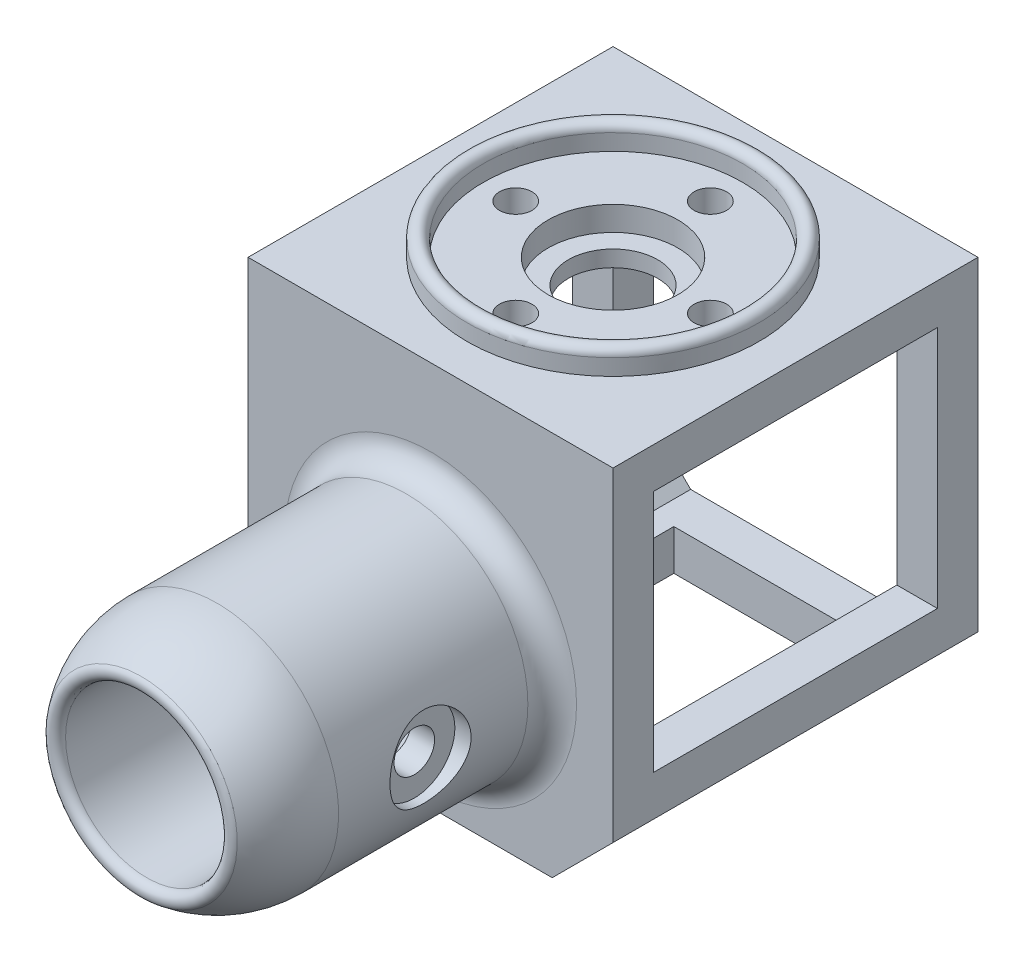
from build123d import *

# Parameters (mm, degrees)
BOSS_EXTRUDE2_DEPTH                      = 45
SHELL1_T                                 = 5
CUT_EXTRUDE1_REACH                       = 47
SKETCH7_W                                = 35
SKETCH7_H                                = 30
CUT_EXTRUDE2_DEPTH                       = 46
CUT_EXTRUDE5_REACH                       = 49.5
SKETCH9_W                                = 20
SKETCH9_H                                = 35
CBORE_FOR_M16_HEX_HEAD_BOLT1_D           = 11
CBORE_FOR_M16_HEX_HEAD_BOLT1_DEPTH       = 5
CBORE_FOR_M16_HEX_HEAD_BOLT1_CBORE_D     = 16
CBORE_FOR_M16_HEX_HEAD_BOLT1_CBORE_DEPTH = 3
CBORE_FOR_M16_HEX_HEAD_BOLT1_TIP         = 3.304733405
CUT_EXTRUDE6_REACH                       = 49.5
SKETCH11_R                               = 2
FILLET1_R                                = 3
CUT_EXTRUDE10_REACH                      = 47
SKETCH15_R                               = 10
CBORE_FOR_M5_HEX_HEAD_BOLT1_D            = 5
CBORE_FOR_M5_HEX_HEAD_BOLT1_CBORE_D      = 10
CBORE_FOR_M5_HEX_HEAD_BOLT1_CBORE_DEPTH  = 2


with BuildPart() as part:
    # Sketch5 → Boss-Extrude2 (new body)
    with BuildSketch(Plane.XY):
        Polygon((-15, -20), (15, -20), (22.5, -12.5), (22.5, 27.5), (-22.5, 27.5), (-22.5, -12.5), align=None)
    extrude(amount=-BOSS_EXTRUDE2_DEPTH)

    # Shell1 (no face opened: a closed hollow body)
    add(offset(amount=-SHELL1_T, mode=Mode.PRIVATE), mode=Mode.SUBTRACT)

    # Sketch6 → Cut-Extrude1 (cut, up to next)
    with BuildSketch(Plane(origin=(0, 0, -45), x_dir=(-1, 0, 0), z_dir=(0, 0, -1)), mode=Mode.PRIVATE) as cut_extrude1_sk1:
        Polygon((12.928932188, -15), (17.5, -10.428932188), (17.5, 22.5), (-17.5, 22.5), (-17.5, -10.428932188), (-12.928932188, -15), align=None)
    cut_extrude1_tool1 = extrude(cut_extrude1_sk1.sketch, amount=-CUT_EXTRUDE1_REACH, mode=Mode.PRIVATE) & part.part
    add(cut_extrude1_tool1.solids().sort_by_distance((0, 4.028675, -45))[0], mode=Mode.SUBTRACT)

    # Sketch7 → Cut-Extrude2 (cut, through all)
    with BuildSketch(Plane(origin=(22.5, 0, 0), x_dir=(0, 0, -1), z_dir=(1, 0, 0))):
        with Locations((22.5, 7.5)):
            Rectangle(SKETCH7_W, SKETCH7_H)
    extrude(amount=-CUT_EXTRUDE2_DEPTH, mode=Mode.SUBTRACT)

    # Sketch9 → Cut-Extrude5 (cut, up to next)
    with BuildSketch(Plane.XZ.offset(20), mode=Mode.PRIVATE) as cut_extrude5_sk1:
        with Locations((0, -22.5)):
            Rectangle(SKETCH9_W, SKETCH9_H)
    cut_extrude5_tool1 = extrude(cut_extrude5_sk1.sketch, amount=-CUT_EXTRUDE5_REACH, mode=Mode.PRIVATE) & part.part
    add(cut_extrude5_tool1.solids().sort_by_distance((0, -20, -22.5))[0], mode=Mode.SUBTRACT)

    # Sketch1 → Revolve1 (revolve)
    with BuildSketch(Plane(origin=(0, 0, 0), x_dir=(0, 0, -1), z_dir=(1, 0, 0)), mode=Mode.PRIVATE) as revolve1_sk:
        with BuildLine():
            Line((0, 10), (-35, 10))
            ThreePointArc((-35, 10), (-35.944911183, 10.672673165), (-35.618589574, 11.785714286))
            ThreePointArc((-35.618589574, 11.785714286), (-31.249648492, 14.173667738), (-26.339745962, 15))
            Line((-26.339745962, 15), (0, 15))
            Line((0, 15), (0, 10))
        make_face()
    revolve(revolve1_sk.sketch.rotate(Axis((0, 0, 0), (0, 0, 1)), 90), axis=Axis((0, 0, 0), (0, 0, 1)))  # turned: the seam where the file's is

    # Sketch10 → Revolve2 (revolve)
    with BuildSketch(Plane(origin=(0, 0, 0), x_dir=(0, 0, -1), z_dir=(1, 0, 0))):
        with BuildLine():
            Line((38.5, 27.5), (38.5, 29.5))
            ThreePointArc((38.5, 29.5), (39.5, 30.5), (40.5, 29.5))
            Line((40.5, 29.5), (40.5, 27.5))
            Line((40.5, 27.5), (38.5, 27.5))
        make_face()
    revolve(axis=Axis((0, 27.5, -22.5), (0, 1, 0)))

    # CBORE for M16 Hex Head Bolt1
    with Locations(Plane(origin=(0, 27.5, 0), x_dir=(1, 0, 0), z_dir=(0, 1, 0))):
        with Locations((0, 22.5)):
            CounterBoreHole(CBORE_FOR_M16_HEX_HEAD_BOLT1_D / 2, CBORE_FOR_M16_HEX_HEAD_BOLT1_CBORE_D / 2, CBORE_FOR_M16_HEX_HEAD_BOLT1_CBORE_DEPTH, depth=CBORE_FOR_M16_HEX_HEAD_BOLT1_DEPTH)
            with Locations((0, 0, -(CBORE_FOR_M16_HEX_HEAD_BOLT1_DEPTH + CBORE_FOR_M16_HEX_HEAD_BOLT1_TIP / 2))):  # 118° drill point
                Cone(0, CBORE_FOR_M16_HEX_HEAD_BOLT1_D / 2, CBORE_FOR_M16_HEX_HEAD_BOLT1_TIP, mode=Mode.SUBTRACT)

    # Sketch11 → Cut-Extrude6 (cut, up to next)
    with BuildSketch(Plane(origin=(0, 27.5, 0), x_dir=(1, 0, 0), z_dir=(0, 1, 0)), mode=Mode.PRIVATE) as cut_extrude6_sk1:
        with Locations(Location((12, 22.5, 0), (0, 0, 270))):  # turned: the seam where the file's is
            Circle(SKETCH11_R)
    cut_extrude6_tool1 = extrude(cut_extrude6_sk1.sketch, amount=-CUT_EXTRUDE6_REACH, mode=Mode.PRIVATE) & part.part
    add(cut_extrude6_tool1.solids().sort_by_distance((12, 27.5, -22.5))[0], mode=Mode.SUBTRACT)
    # Sketch11 → Cut-Extrude6 (cut, up to next)
    with BuildSketch(Plane(origin=(0, 27.5, 0), x_dir=(1, 0, 0), z_dir=(0, 1, 0)), mode=Mode.PRIVATE) as cut_extrude6_sk2:
        with Locations(Location((0, 10.5, 0), (0, 0, 270))):  # turned: the seam where the file's is
            Circle(SKETCH11_R)
    cut_extrude6_tool2 = extrude(cut_extrude6_sk2.sketch, amount=-CUT_EXTRUDE6_REACH, mode=Mode.PRIVATE) & part.part
    add(cut_extrude6_tool2.solids().sort_by_distance((0, 27.5, -10.5))[0], mode=Mode.SUBTRACT)
    # Sketch11 → Cut-Extrude6 (cut, up to next)
    with BuildSketch(Plane(origin=(0, 27.5, 0), x_dir=(1, 0, 0), z_dir=(0, 1, 0)), mode=Mode.PRIVATE) as cut_extrude6_sk3:
        with Locations(Location((-12, 22.5, 0), (0, 0, 270))):  # turned: the seam where the file's is
            Circle(SKETCH11_R)
    cut_extrude6_tool3 = extrude(cut_extrude6_sk3.sketch, amount=-CUT_EXTRUDE6_REACH, mode=Mode.PRIVATE) & part.part
    add(cut_extrude6_tool3.solids().sort_by_distance((-12, 27.5, -22.5))[0], mode=Mode.SUBTRACT)
    # Sketch11 → Cut-Extrude6 (cut, up to next)
    with BuildSketch(Plane(origin=(0, 27.5, 0), x_dir=(1, 0, 0), z_dir=(0, 1, 0)), mode=Mode.PRIVATE) as cut_extrude6_sk4:
        with Locations(Location((0, 34.5, 0), (0, 0, 270))):  # turned: the seam where the file's is
            Circle(SKETCH11_R)
    cut_extrude6_tool4 = extrude(cut_extrude6_sk4.sketch, amount=-CUT_EXTRUDE6_REACH, mode=Mode.PRIVATE) & part.part
    add(cut_extrude6_tool4.solids().sort_by_distance((0, 27.5, -34.5))[0], mode=Mode.SUBTRACT)

    # Fillet1
    fillet1_edges = [part.edges().sort_by_distance(p)[0] for p in [
        (15, 0, 0),
    ]]
    fillet(fillet1_edges, radius=FILLET1_R)

    # Sketch15 → Cut-Extrude10 (cut, up to next)
    with BuildSketch(Plane.XY, mode=Mode.PRIVATE) as cut_extrude10_sk1:
        with Locations(Location((0, 0, 0), (0, 0, 180))):  # turned: the seam where the file's is
            Circle(SKETCH15_R)
    cut_extrude10_tool1 = extrude(cut_extrude10_sk1.sketch, amount=-CUT_EXTRUDE10_REACH, mode=Mode.PRIVATE) & part.part
    add(cut_extrude10_tool1.solids().sort_by_distance((0, 0, 0))[0], mode=Mode.SUBTRACT)

    # CBORE for M5 Hex Head Bolt1 (through all)
    with Locations(Plane(origin=(15, 0, 0), x_dir=(0, 0, -1), z_dir=(1, 0, 0))):
        with Locations((-15, 0)):
            cbore_for_m5_hex_head_bolt1 = CounterBoreHole(CBORE_FOR_M5_HEX_HEAD_BOLT1_D / 2, CBORE_FOR_M5_HEX_HEAD_BOLT1_CBORE_D / 2, CBORE_FOR_M5_HEX_HEAD_BOLT1_CBORE_DEPTH)

    # Mirror1: CBORE for M5 Hex Head Bolt1 across plane
    add(cbore_for_m5_hex_head_bolt1.mirror(Plane(origin=(0, 0, 0), x_dir=(0, 0, 1), z_dir=(1, 0, 0))), mode=Mode.SUBTRACT)


solid = part.part
